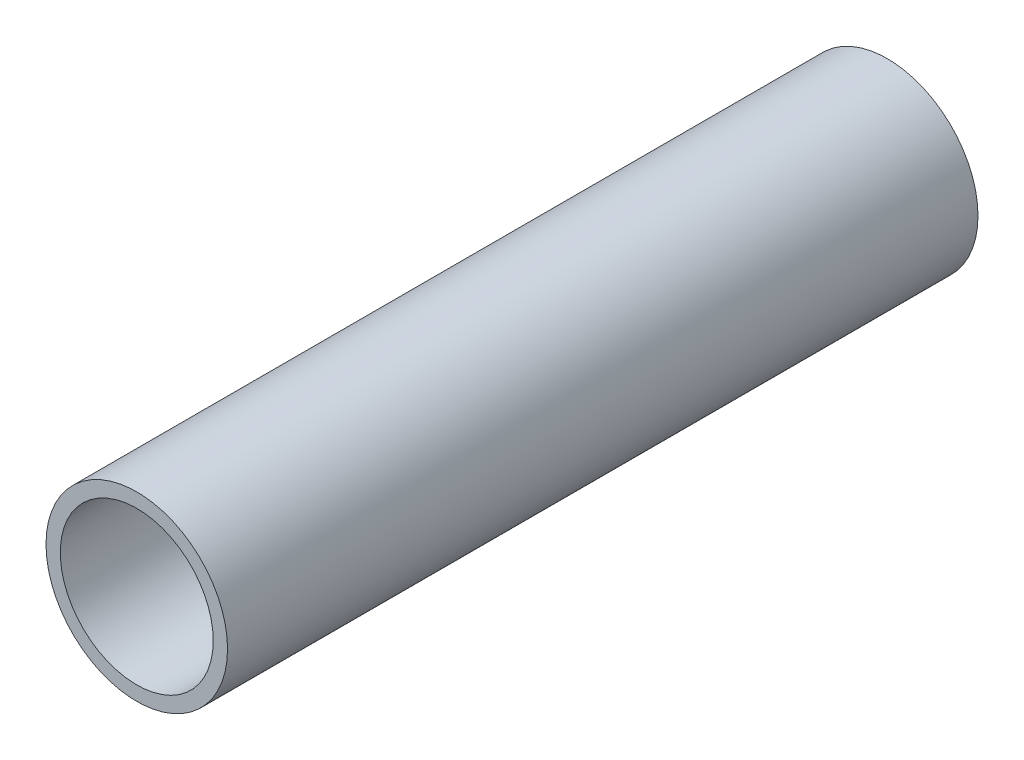
from build123d import *

# Parameters (mm, degrees)
SKETCH1_R           = 12.7
SKETCH1_R_2         = 10.7
BOSS_EXTRUDE1_DEPTH = 105


with BuildPart() as part:
    # Sketch1 → Boss-Extrude1 (new body)
    with BuildSketch(Plane.XY):
        Circle(SKETCH1_R)
        Circle(SKETCH1_R_2, mode=Mode.SUBTRACT)
    extrude(amount=BOSS_EXTRUDE1_DEPTH)


solid = part.part
